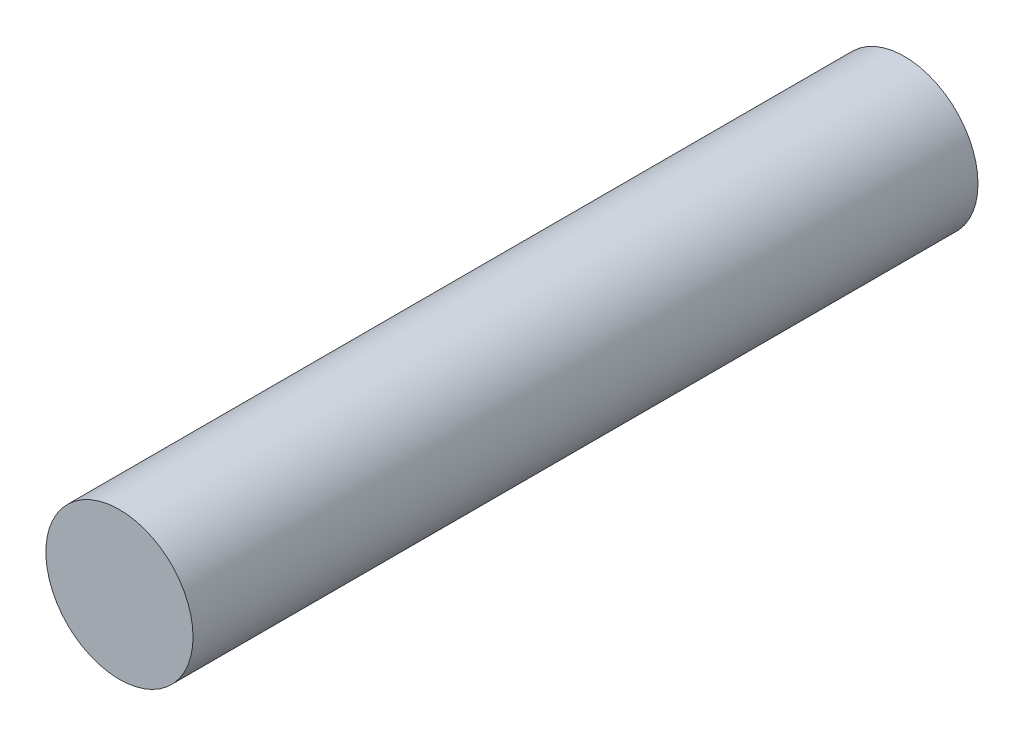
from build123d import *

# Parameters (mm, degrees)
SKETCH_1_R      = 1.5
EXTRUDE_1_DEPTH = 16


with BuildPart() as part:
    # ｽｹｯﾁ1 → ﾎﾞｽ - 押し出し1 (new body)
    with BuildSketch(Plane.XY):
        Circle(SKETCH_1_R)
    extrude(amount=EXTRUDE_1_DEPTH)


solid = part.part
